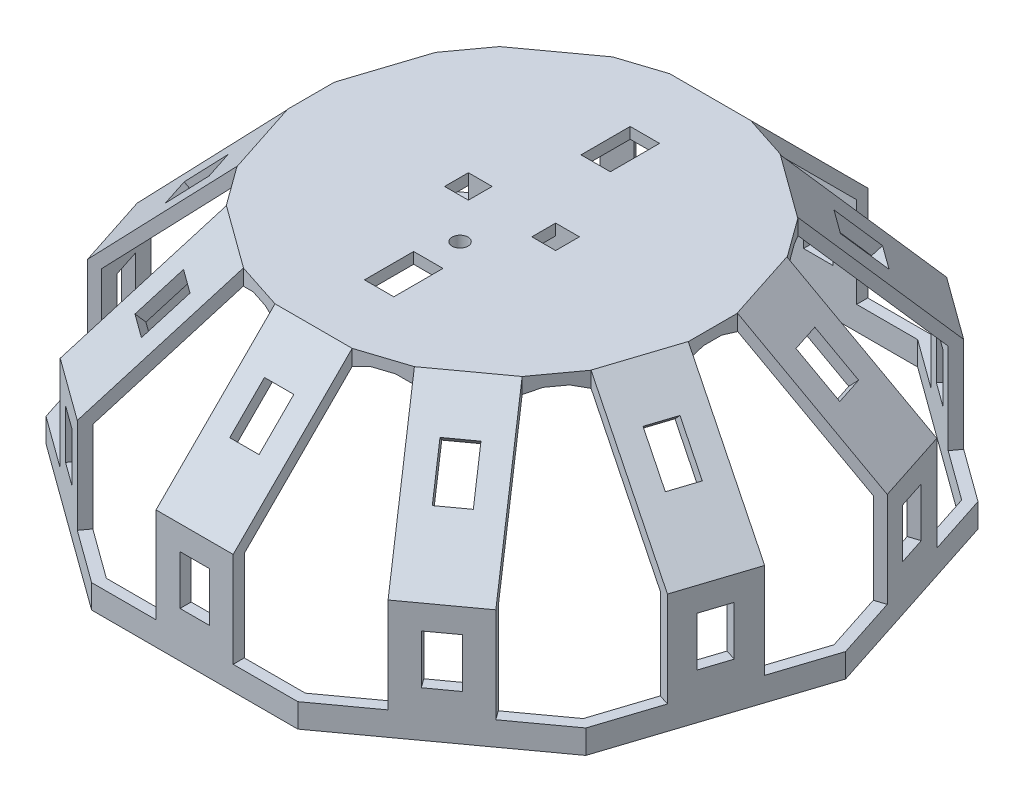
from build123d import *

# Parameters (mm, degrees)
BOSS_EXTRUDE1_DEPTH = 30
CHAMFER1_SIZE       = 15
SHELL1_T            = -1.4
SKETCH6_W           = 3.7
SKETCH6_H           = 6.2
CUT_EXTRUDE6_DEPTH  = 10
SKETCH4_W           = 3.7
SKETCH4_H           = 6.2
CUT_EXTRUDE4_DEPTH  = 10
SKETCH5_W           = 3.7
SKETCH5_H           = 6.2
CUT_EXTRUDE5_DEPTH  = 10
CIRPATTERN7_COUNT   = 10
CUT_EXTRUDE8_DEPTH  = 27
CIRPATTERN9_COUNT   = 10
SKETCH9_R           = 1
SKETCH9_W           = 3
SKETCH9_H           = 3
CUT_EXTRUDE9_DEPTH  = 1.4
SKETCH10_W          = 14
SKETCH10_H          = 2
BOSS_EXTRUDE2_DEPTH = 4


with BuildPart() as part:
    # Sketch1 → Boss-Extrude1 (new body)
    with BuildSketch(Plane(origin=(0, 0, 0), x_dir=(1, 0, 0), z_dir=(0, 1, 0))):
        Polygon((-34.026032334, -24.72135955), (-12.996787849, -40), (12.996787849, -40), (34.026032334, -24.72135955), (42.05848897, 0), (34.026032334, 24.72135955), (12.996787849, 40), (-12.996787849, 40), (-34.026032334, 24.72135955), (-42.05848897, 0), align=None)
    extrude(amount=BOSS_EXTRUDE1_DEPTH)

    # Chamfer1
    chamfer1_edges = [part.edges().sort_by_distance(p)[0] for p in [
        (23.511410092, 30, -32.360679775),
        (0, 30, -40),
        (-23.511410092, 30, -32.360679775),
        (-38.042260652, 30, -12.360679775),
        (-38.042260652, 30, 12.360679775),
        (-23.511410092, 30, 32.360679775),
        (0, 30, 40),
        (23.511410092, 30, 32.360679775),
        (38.042260652, 30, 12.360679775),
        (38.042260652, 30, -12.360679775),
    ]]
    chamfer(chamfer1_edges, length=CHAMFER1_SIZE)

    # Shell1
    shell1_openings = [part.faces().sort_by_distance(p)[0] for p in [
        (0, 0, 0),
    ]]
    offset(amount=SHELL1_T, openings=shell1_openings, kind=Kind.INTERSECTION)

    # Sketch6 → Cut-Extrude6 (cut)
    with BuildSketch(Plane(origin=(0, 30, 0), x_dir=(1, 0, 0), z_dir=(0, 1, 0))):
        with Locations((0, -13.65)):
            Rectangle(SKETCH6_W, SKETCH6_H)
        with Locations((0, 13.65)):
            Rectangle(SKETCH6_W, SKETCH6_H)
    extrude(amount=-CUT_EXTRUDE6_DEPTH, mode=Mode.SUBTRACT)

    # Sketch4 → Cut-Extrude4 (cut)
    with BuildSketch(Plane.XY.offset(40)):
        with Locations((0, 8.85)):
            Rectangle(SKETCH4_W, SKETCH4_H)
    cut_extrude4 = extrude(amount=-CUT_EXTRUDE4_DEPTH, mode=Mode.SUBTRACT)

    # Sketch5 → Cut-Extrude5 (cut)
    with BuildSketch(Plane(origin=(0, 27.5, 27.5), x_dir=(1, 0, 0), z_dir=(0, 0.707106781, 0.707106781))):
        with Locations((0, -5.721067812)):
            Rectangle(SKETCH5_W, SKETCH5_H)
    cut_extrude5 = extrude(amount=-CUT_EXTRUDE5_DEPTH, mode=Mode.SUBTRACT)

    # CirPattern7: Cut-Extrude4, Cut-Extrude5 ×10 about axis
    cirpattern7_axis = Axis((0, 0, 0), (0, 1, 0))
    for i in range(1, CIRPATTERN7_COUNT):
        add(cut_extrude4.rotate(cirpattern7_axis, i * 360 / CIRPATTERN7_COUNT), mode=Mode.SUBTRACT)
        add(cut_extrude5.rotate(cirpattern7_axis, i * 360 / CIRPATTERN7_COUNT), mode=Mode.SUBTRACT)

    # Sketch8 → Cut-Extrude8 (cut)
    with BuildSketch(Plane(origin=(0, 30, 0), x_dir=(1, 0, 0), z_dir=(0, 1, 0))):
        Polygon((10.770898885, -23.076183333), (19.587677669, -35.211438249), (12.996787849, -40), (4.85, -40), (4.85, -25), align=None)
    cut_extrude8 = extrude(amount=-CUT_EXTRUDE8_DEPTH, mode=Mode.SUBTRACT)

    # CirPattern9: Cut-Extrude8 ×10 about axis
    cirpattern9_axis = Axis((-0.012573815, 0, -0.038698225), (0, 1, 0))
    for i in range(1, CIRPATTERN9_COUNT):
        add(cut_extrude8.rotate(cirpattern9_axis, i * 360 / CIRPATTERN9_COUNT), mode=Mode.SUBTRACT)

    # Sketch9 → Cut-Extrude9 (cut)
    with BuildSketch(Plane(origin=(0, 30, 0), x_dir=(1, 0, 0), z_dir=(0, 1, 0))):
        with Locations((0, -6.55)):
            Circle(SKETCH9_R)
        with Locations((5.5, 0)):
            Rectangle(SKETCH9_W, SKETCH9_H)
        with Locations((-5.5, 0)):
            Rectangle(SKETCH9_W, SKETCH9_H)
    extrude(amount=-CUT_EXTRUDE9_DEPTH, mode=Mode.SUBTRACT)

    # Sketch10 → Boss-Extrude2 (add)
    with BuildSketch(Plane.XZ.offset(-28.6)):
        with Locations((0, 2.5)):
            Rectangle(SKETCH10_W, SKETCH10_H)
        with Locations((0, -2.5)):
            Rectangle(SKETCH10_W, SKETCH10_H)
    extrude(amount=BOSS_EXTRUDE2_DEPTH)


solid = part.part
